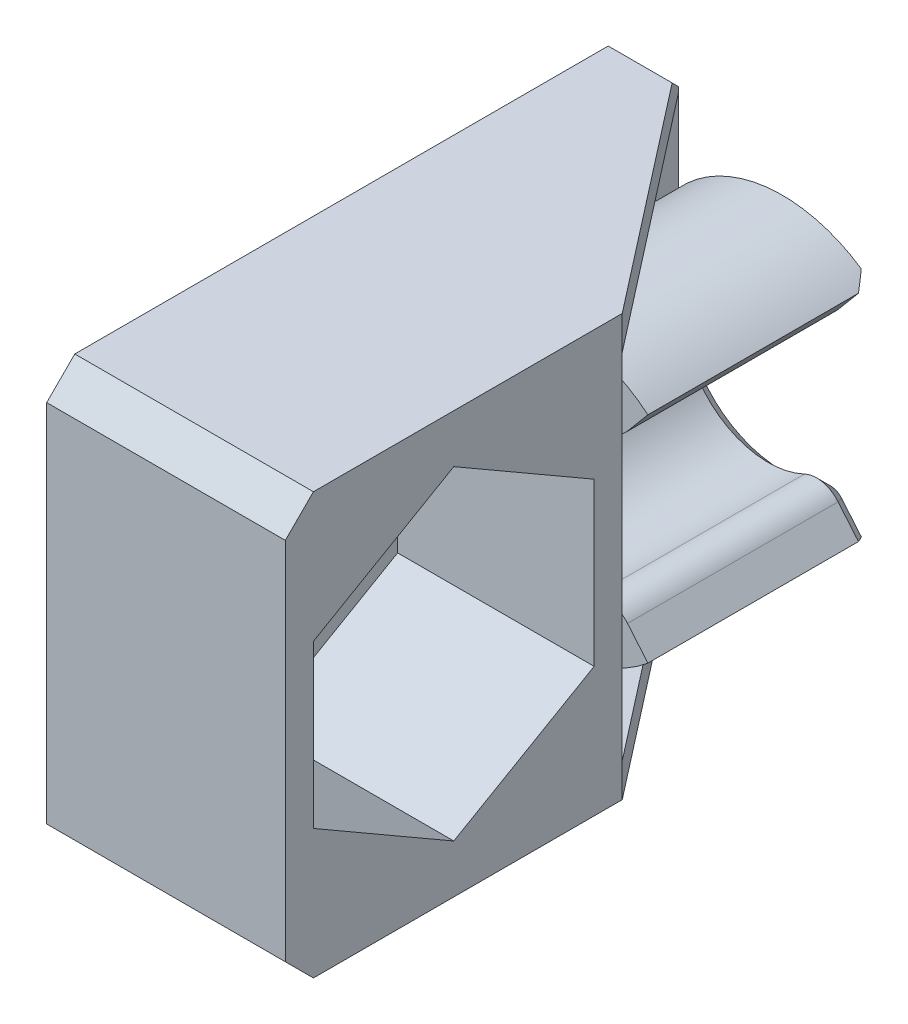
from build123d import *

# Parameters (mm, degrees)
SALIENTE_EXTRUIR1_DEPTH = 8
CROQUIS3_W              = 21
CROQUIS3_H              = 15
SALIENTE_EXTRUIR2_DEPTH = 1.5
CROQUIS4_R              = 3
CORTAR_EXTRUIR1_DEPTH   = 9.413938048
CROQUIS5_W              = 12
CROQUIS5_H              = 15
SALIENTE_EXTRUIR3_DEPTH = 7
CORTAR_EXTRUIR2_DEPTH   = 7
REDONDEO1_R             = 1
CHAFL_N1_SIZE           = 0.5
SALIENTE_EXTRUIR4_DEPTH = 1.2
CHAFL_N2_SIZE           = 1


with BuildPart() as part:
    # Croquis1 → Saliente-Extruir1 (new body)
    with BuildSketch(Plane.XY):
        with BuildLine():
            Line((1.928362829, 2.298133329), (3.213938048, 3.830222216))
            ThreePointArc((3.213938048, 3.830222216), (-0.868240888, 4.924038765), (-4.330127019, 2.5))
            Line((-4.330127019, 2.5), (-5.2, 2.5))
            Line((-5.2, 2.5), (-5.2, -2.5))
            Line((-5.2, -2.5), (-4.330127019, -2.5))
            ThreePointArc((-4.330127019, -2.5), (-0.868240888, -4.924038765), (3.213938048, -3.830222216))
            Line((3.213938048, -3.830222216), (1.928362829, -2.298133329))
            ThreePointArc((1.928362829, -2.298133329), (-3, 0), (1.928362829, 2.298133329))
        make_face()
    extrude(amount=SALIENTE_EXTRUIR1_DEPTH)

    # Croquis3 → Saliente-Extruir2 (add)
    with BuildSketch(Plane.ZY.offset(5.2)):
        with Locations((10.5, 0)):
            Rectangle(CROQUIS3_W, CROQUIS3_H)
    extrude(amount=-SALIENTE_EXTRUIR2_DEPTH)

    # Croquis4 → Cortar-Extruir1 (cut, through all)
    with BuildSketch(Plane.ZY.offset(5.2)):
        with Locations((15, 0)):
            Circle(CROQUIS4_R)
    extrude(amount=-CORTAR_EXTRUIR1_DEPTH, mode=Mode.SUBTRACT)

    # Croquis5 → Saliente-Extruir3 (add)
    with BuildSketch(Plane(origin=(-3.7, 0, 0), x_dir=(0, 0, -1), z_dir=(1, 0, 0))):
        with Locations((-15, 0)):
            Rectangle(CROQUIS5_W, CROQUIS5_H)
    extrude(amount=SALIENTE_EXTRUIR3_DEPTH)

    # Croquis7 → Cortar-Extruir2 (cut)
    with BuildSketch(Plane(origin=(3.3, 0, 0), x_dir=(0, 0, -1), z_dir=(1, 0, 0))):
        Polygon((-10, -2.886751346), (-10, 2.886751346), (-15, 5.773502692), (-20, 2.886751346), (-20, -2.886751346), (-15, -5.773502692), align=None)
    extrude(amount=-CORTAR_EXTRUIR2_DEPTH, mode=Mode.SUBTRACT)

    # Redondeo1
    redondeo1_edges = [part.edges().sort_by_distance(p)[0] for p in [
        (1.928362829, -2.298133329, 4),
        (1.928362829, 2.298133329, 4),
    ]]
    fillet(redondeo1_edges, radius=REDONDEO1_R)

    # Chaflán1
    chafl_n1_edges = [part.edges().sort_by_distance(p)[0] for p in [
        (-3, 0, 0),
        (2.851721878, -3.398549793, 0),
        (2.851721878, 3.398549793, 0),
        (1.935447157, 2.632392254, 0),
        (1.935447157, -2.632392254, 0),
    ]]
    chamfer(chafl_n1_edges, length=CHAFL_N1_SIZE)

    # Croquis8 → Saliente-Extruir4 (add)
    with BuildSketch(Plane(origin=(0, 7.5, 0), x_dir=(1, 0, 0), z_dir=(0, 1, 0))):
        Polygon((-3.7, 0), (3.3, -9), (-3.7, -9), align=None)
    saliente_extruir4 = extrude(amount=-SALIENTE_EXTRUIR4_DEPTH)

    # Simetría1: Saliente-Extruir4 across plane
    add(saliente_extruir4.mirror(Plane.ZX))

    # Chaflán2
    chafl_n2_edges = [part.edges().sort_by_distance(p)[0] for p in [
        (-4.45, -7.5, 0),
        (-4.45, 7.5, 0),
        (-0.95, 7.5, 21),
        (-0.95, -7.5, 21),
    ]]
    chamfer(chafl_n2_edges, length=CHAFL_N2_SIZE)


solid = part.part
